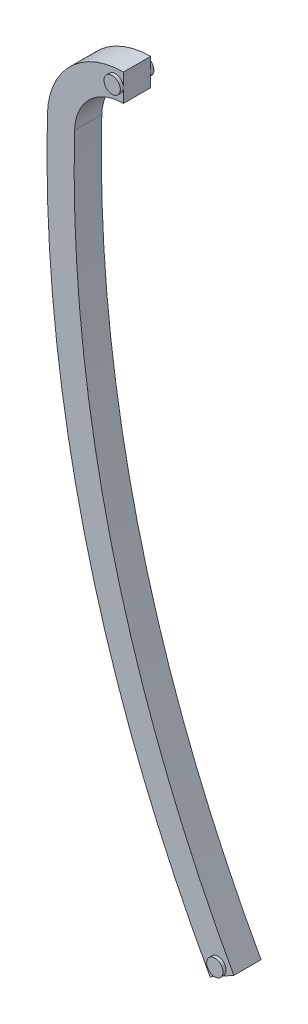
from build123d import *

# Parameters (mm, degrees)
BOSS_EXTRUDE1_DEPTH = 3.175
SKETCH3_R           = 0.9525
BOSS_EXTRUDE3_DEPTH = 1.9625


with BuildPart() as part:
    # Sketch1 → Boss-Extrude1 (new body)
    with BuildSketch(Plane.XY):
        with BuildLine():
            Line((-149.172401421, 3.961726818), (-152.346282302, 4.046018878))
            ThreePointArc((-152.346282302, 4.046018878), (-149.661588923, 10.179078671), (-143.459415834, 12.70000111))
            Line((-143.459415834, 12.70000111), (-143.459415834, 9.52500111))
            ThreePointArc((-143.459415834, 9.52500111), (-147.446527106, 7.904408113), (-149.172401421, 3.961726818))
        make_face()
        with BuildLine():
            ThreePointArc((-149.172401421, 3.961726818), (-144.969011945, -35.384830091), (-130.57187557, -72.243241449))
            Line((-130.57187557, -72.243241449), (-133.350000583, -73.780331692))
            ThreePointArc((-133.350000583, -73.780331692), (-148.053459008, -36.137698816), (-152.346282302, 4.046018878))
            Line((-152.346282302, 4.046018878), (-149.172401421, 3.961726818))
        make_face()
    extrude(amount=BOSS_EXTRUDE1_DEPTH)

    # Sketch3 → Boss-Extrude3 (add, symmetric)
    with BuildSketch(Plane(origin=(0, 0, 1.5875), x_dir=(-1, 0, 0), z_dir=(0, 0, -1))):
        with Locations((144.411915834, 11.11250111)):
            Circle(SKETCH3_R)
        with Locations((132.42206515, -72.178349067)):
            Circle(SKETCH3_R)
    extrude(amount=BOSS_EXTRUDE3_DEPTH, both=True)


solid = part.part
